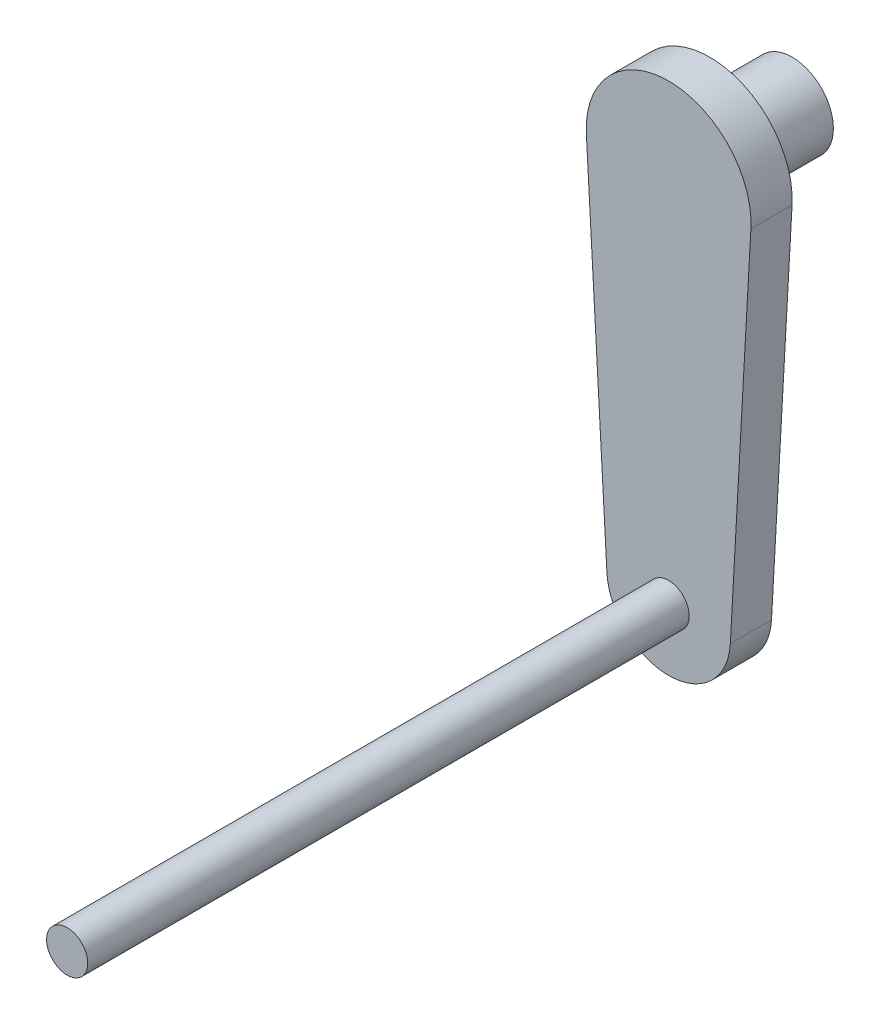
from build123d import *

# Parameters (mm, degrees)
SKETCH1_R           = 6.35
BOSS_EXTRUDE1_DEPTH = 12.7
SKETCH1_3_R         = 3.175
BOSS_EXTRUDE2_DEPTH = 6.35
SKETCH1_4_R         = 3.175
BOSS_EXTRUDE3_DEPTH = 99.06


with BuildPart() as part:
    # Sketch1 → Boss-Extrude1 (new body)
    with BuildSketch(Plane.XY):
        Circle(SKETCH1_R)
    extrude(amount=-BOSS_EXTRUDE1_DEPTH)

    # Sketch1_3 → Boss-Extrude2 (add)
    with BuildSketch(Plane.XY):
        with BuildLine():
            Line((9.510289567, -57.679166667), (12.680386089, -0.705555556))
            ThreePointArc((12.680386089, -0.705555556), (0, 12.7), (-12.680386089, -0.705555556))
            Line((-12.680386089, -0.705555556), (-9.510289567, -57.679166667))
            ThreePointArc((-9.510289567, -57.679166667), (0, -66.675), (9.510289567, -57.679166667))
        make_face()
        with Locations((0, -57.15)):
            Circle(SKETCH1_3_R, mode=Mode.SUBTRACT)
    extrude(amount=BOSS_EXTRUDE2_DEPTH)

    # Sketch1_4 → Boss-Extrude3 (add)
    with BuildSketch(Plane.XY):
        with Locations((0, -57.15)):
            Circle(SKETCH1_4_R)
    extrude(amount=BOSS_EXTRUDE3_DEPTH)


solid = part.part
